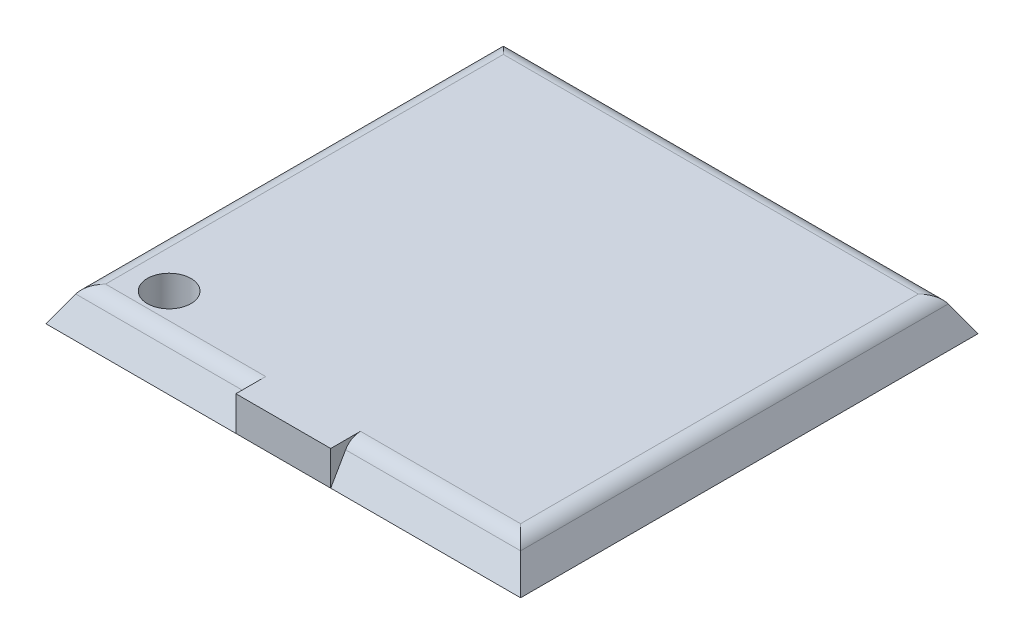
from build123d import *

# Parameters (mm, degrees)
SKETCH1_W           = 27.6
SKETCH1_H           = 26.6
BOSS_EXTRUDE1_DEPTH = 2
BOSS_EXTRUDE1_TAPER = 30
SKETCH2_W           = 5.514509834
SKETCH2_H           = 2
BOSS_EXTRUDE2_DEPTH = 13.3
SKETCH3_R           = 1.27
CUT_EXTRUDE1_DEPTH  = 3.0000001
FILLET5_R           = 1


with BuildPart() as part:
    # Sketch1 → Boss-Extrude1 (new body)
    with BuildSketch(Plane(origin=(0, 0, 0), x_dir=(1, 0, 0), z_dir=(0, 1, 0))):
        Rectangle(SKETCH1_W, SKETCH1_H)
    extrude(amount=BOSS_EXTRUDE1_DEPTH, taper=BOSS_EXTRUDE1_TAPER)

    # Sketch2 → Boss-Extrude2 (add)
    with BuildSketch(Plane.XY):
        with Locations((0, 1)):
            Rectangle(SKETCH2_W, SKETCH2_H)
    extrude(amount=BOSS_EXTRUDE2_DEPTH)

    # Sketch3 → Cut-Extrude1 (cut, through all)
    with BuildSketch(Plane(origin=(0, 0, 0), x_dir=(1, 0, 0), z_dir=(0, 1, 0))):
        with Locations((-9.87, -10.07)):
            Circle(SKETCH3_R)
    extrude(amount=CUT_EXTRUDE1_DEPTH, mode=Mode.SUBTRACT)

    # Fillet5
    fillet5_edges = [part.edges().sort_by_distance(p)[0] for p in [
        (-12.645299462, 2, 0),
        (-7.701277189, 2, 12.145299462),
        (7.701277189, 2, 12.145299462),
        (12.645299462, 2, 0),
        (0, 2, -12.145299462),
    ]]
    fillet(fillet5_edges, radius=FILLET5_R)


solid = part.part
